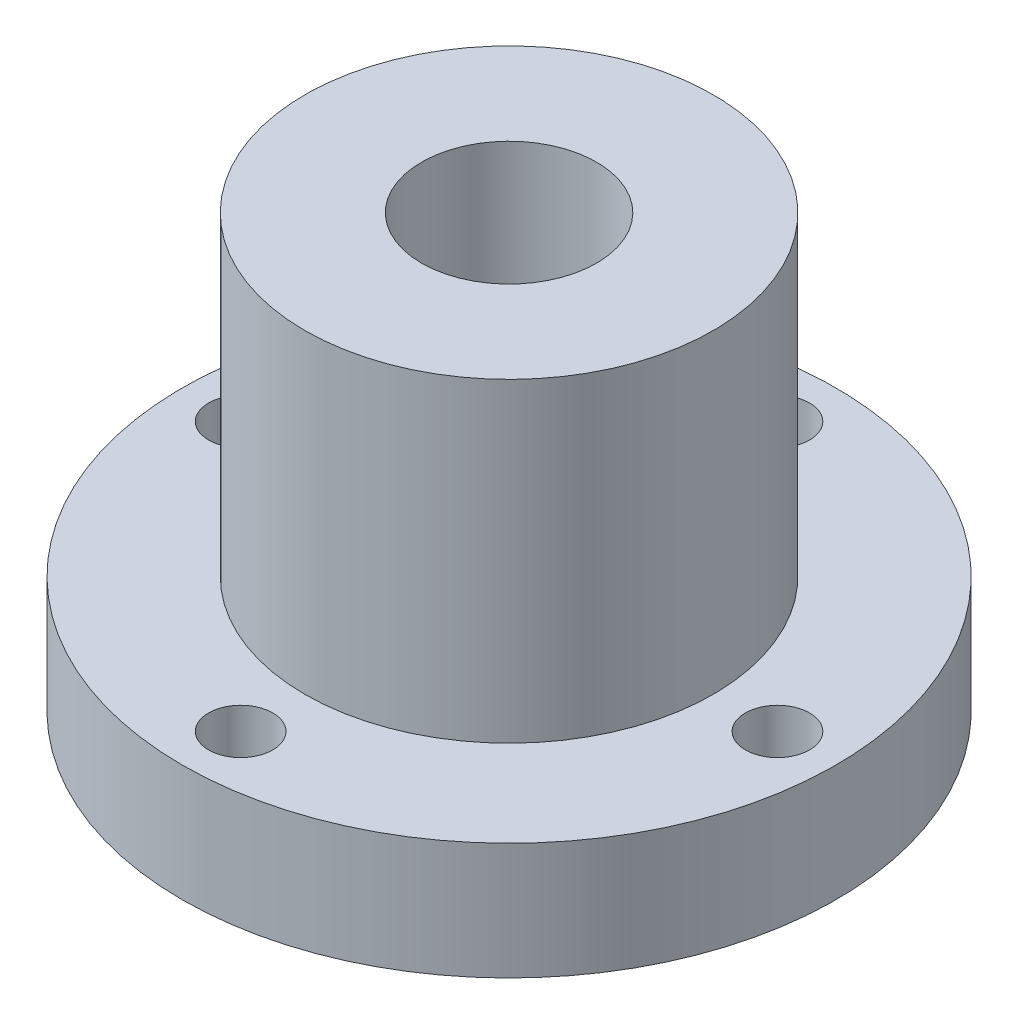
from build123d import *

# Parameters (mm, degrees)
SKETCH_1_R          = 28
SKETCH_1_R_2        = 7.5
EXTRUDE_1_DEPTH     = 10
SKETCH_2_R          = 17.5
SKETCH_2_R_2        = 7.5
EXTRUDE_2_DEPTH     = 27
SKETCH_3_R          = 2.75
CUT_EXTRUDE_1_DEPTH = 27


with BuildPart() as part:
    # 草图1 → 凸台-拉伸1 (new body)
    with BuildSketch(Plane(origin=(0, 0, 0), x_dir=(1, 0, 0), z_dir=(0, 1, 0))):
        Circle(SKETCH_1_R)
        Circle(SKETCH_1_R_2, mode=Mode.SUBTRACT)
    extrude(amount=EXTRUDE_1_DEPTH)

    # 草图2 → 凸台-拉伸2 (add)
    with BuildSketch(Plane(origin=(0, 10, 0), x_dir=(1, 0, 0), z_dir=(0, 1, 0))):
        Circle(SKETCH_2_R)
        Circle(SKETCH_2_R_2, mode=Mode.SUBTRACT)
    extrude(amount=EXTRUDE_2_DEPTH)

    # 草图3 → 切除-拉伸1 (cut)
    with BuildSketch(Plane(origin=(0, 10, 0), x_dir=(1, 0, 0), z_dir=(0, 1, 0))):
        with Locations((0, 23)):
            Circle(SKETCH_3_R)
        with Locations((23, 0)):
            Circle(SKETCH_3_R)
        with Locations((0, -23)):
            Circle(SKETCH_3_R)
        with Locations((-23, 0)):
            Circle(SKETCH_3_R)
    extrude(amount=-CUT_EXTRUDE_1_DEPTH, mode=Mode.SUBTRACT)


solid = part.part
